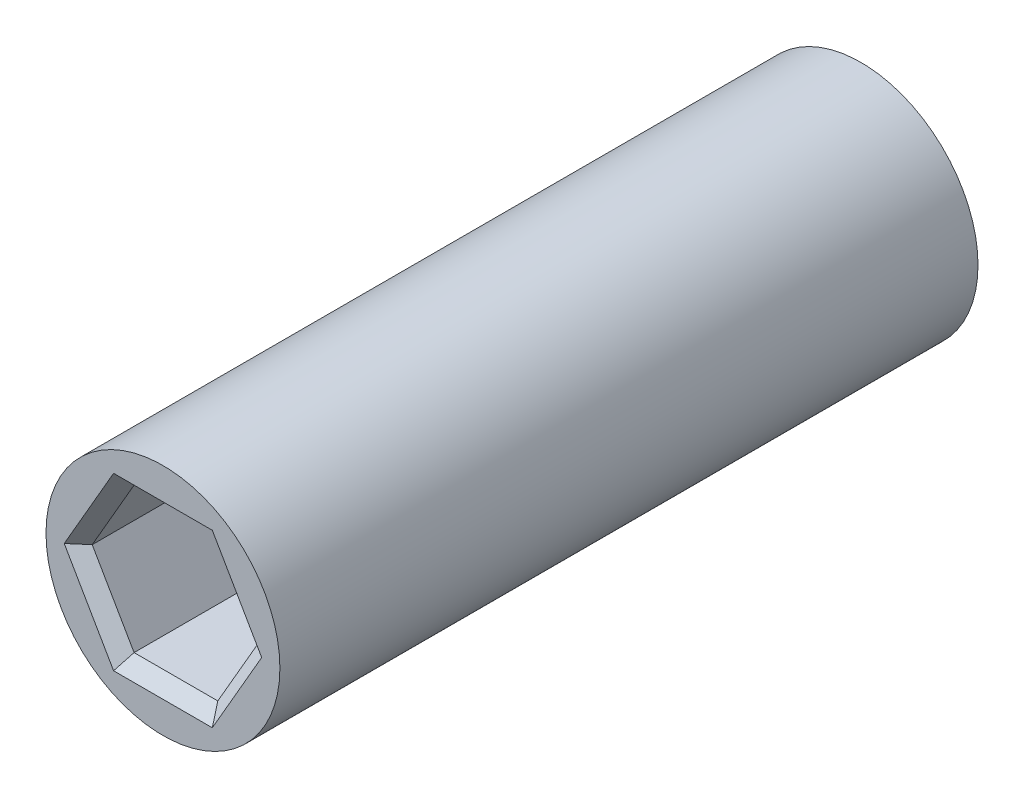
from build123d import *

# Parameters (mm, degrees)
SKETCH1_W          = 4.5
SKETCH1_H          = 26.85997733
CUT_EXTRUDE1_DEPTH = 7
CUT_EXTRUDE2_DEPTH = 7
CHAMFER1_SIZE      = 0.5
CUT_EXTRUDE3_DEPTH = 1


with BuildPart() as part:
    # Sketch1 → Revolve-Thin1 (revolve)
    with BuildSketch(Plane(origin=(0, 0, 0), x_dir=(1, 0, 0), z_dir=(0, 1, 0))):
        with Locations((2.25, 30.929988665)):
            Rectangle(SKETCH1_W, SKETCH1_H)
    revolve(axis=Axis((0, 0, 0), (0, 0, -1)))

    # Sketch2 → Cut-Extrude1 (cut)
    with BuildSketch(Plane.XY.offset(-17.5)):
        Polygon((1.610807251, 2.79), (-1.610807251, 2.79), (-3.221614502, 0), (-1.610807251, -2.79), (1.610807251, -2.79), (3.221614502, 0), align=None)
    extrude(amount=-CUT_EXTRUDE1_DEPTH, mode=Mode.SUBTRACT)

    # Sketch3 → Cut-Extrude2 (cut)
    with BuildSketch(Plane(origin=(0, 0, -44.35997733), x_dir=(-1, 0, 0), z_dir=(0, 0, -1))):
        Polygon((1.610807251, 2.79), (-1.610807251, 2.79), (-3.221614502, 0), (-1.610807251, -2.79), (1.610807251, -2.79), (3.221614502, 0), align=None)
    extrude(amount=-CUT_EXTRUDE2_DEPTH, mode=Mode.SUBTRACT)

    # Chamfer1
    chamfer1_edges = [part.edges().sort_by_distance(p)[0] for p in [
        (2.416210877, 1.395, -17.5),
        (0, 2.79, -17.5),
        (-2.416210877, 1.395, -17.5),
        (-2.416210877, -1.395, -17.5),
        (0, -2.79, -17.5),
        (2.416210877, -1.395, -17.5),
        (-2.416210877, 1.395, -44.35997733),
        (0, 2.79, -44.35997733),
        (2.416210877, 1.395, -44.35997733),
        (2.416210877, -1.395, -44.35997733),
        (0, -2.79, -44.35997733),
        (-2.416210877, -1.395, -44.35997733),
    ]]
    chamfer(chamfer1_edges, length=CHAMFER1_SIZE)

    # Sketch4 → Cut-Extrude3 (cut)
    with BuildSketch(Plane(origin=(0, -4.5, 0), x_dir=(1, 0, 0), z_dir=(0, 1, 0))):
        with BuildLine():
            Line((-0.735236378, 34.104988665), (-0.183809095, 34.104988665))
            add(Edge.make_bspline(
                [(-0.183809095, 34.104988665), (-0.142887229, 34.104821435), (-0.063984952, 34.104498996), (0.049479088, 34.099913909), (0.153619775, 34.092996425), (0.248313279, 34.083867435), (0.333638661, 34.071201473), (0.40941848, 34.055993448), (0.47613676, 34.039057193), (0.516147477, 34.02331892), (0.534890825, 34.015946197)],
                knots=[0, 0, 0, 0, 0.000122758, 0.000236692, 0.000340599, 0.000435844, 0.000522015, 0.000599225, 0.000667726, 0.000728098, 0.000728098, 0.000728098, 0.000728098], degree=3))
            add(Edge.make_bspline(
                [(0.534890825, 34.015946197), (0.555993425, 34.006429933), (0.597245667, 33.987827142), (0.656357727, 33.95629427), (0.711711569, 33.922324809), (0.762389804, 33.884637999), (0.8094619, 33.84482071), (0.852635966, 33.802494227), (0.891564361, 33.757008969), (0.926655631, 33.709180776), (0.957858636, 33.659071505), (0.984643202, 33.606434054), (1.007803352, 33.551714066), (1.025889509, 33.49431609), (1.04092128, 33.434929127), (1.050643284, 33.373178483), (1.057485172, 33.309272455), (1.058047365, 33.265888615), (1.058333333, 33.243820796)],
                knots=[0, 0, 0, 0, 6.9431e-05, 0.000135726, 0.000200852, 0.000264074, 0.000324989, 0.000385705, 0.00044524, 0.000504393, 0.000563519, 0.000622115, 0.000681412, 0.000741551, 0.000802483, 0.00086501, 0.000928929, 0.000995103, 0.000995103, 0.000995103, 0.000995103], degree=3))
            add(Edge.make_bspline(
                [(1.058333333, 33.243820796), (1.057660809, 33.216664827), (1.056333136, 33.163054546), (1.047657842, 33.083998974), (1.031477343, 33.008136947), (1.009687089, 32.93522949), (0.982690716, 32.864804536), (0.947875359, 32.798087533), (0.907633136, 32.733916018), (0.861157476, 32.67313132), (0.809209736, 32.61517584), (0.749228296, 32.563460322), (0.684531415, 32.51450675), (0.612461254, 32.471597247), (0.53499992, 32.431738139), (0.45038063, 32.397967081), (0.360191554, 32.366801607), (0.296952619, 32.351203721), (0.264583333, 32.343219835)],
                knots=[0, 0, 0, 0, 8.1472e-05, 0.00016084, 0.000238178, 0.00031384, 0.000388957, 0.000464053, 0.000539224, 0.00061593, 0.000693367, 0.000772226, 0.000853128, 0.000936463, 0.001023502, 0.00111421, 0.001209545, 0.001309511, 0.001309511, 0.001309511, 0.001309511], degree=3))
            Line((0.264583333, 32.343219835), (0.997275641, 30.929988665))
            Line((0.997275641, 30.929988665), (0.360621995, 30.929988665))
            Line((0.360621995, 30.929988665), (-0.356805889, 32.313963024))
            Line((-0.356805889, 32.313963024), (-0.41023137, 32.313963024))
            Line((-0.41023137, 32.313963024), (-0.605488782, 30.929988665))
            Line((-0.605488782, 30.929988665), (-1.180448718, 30.929988665))
            Line((-1.180448718, 30.929988665), (-0.735236378, 34.104988665))
        make_face()
        with BuildLine():
            add(Edge.make_bspline(
                [(-0.335817308, 32.843129691), (-0.294894066, 32.843508532), (-0.2166182, 32.84423316), (-0.104827079, 32.849303715), (-0.004219131, 32.857224722), (0.08509361, 32.868749131), (0.16339231, 32.882182886), (0.230523904, 32.899038904), (0.286593934, 32.919072013), (0.332485643, 32.942831056), (0.369661123, 32.970726112), (0.40183809, 33.00049459), (0.428631207, 33.033817084), (0.450737928, 33.070134204), (0.467788114, 33.109521218), (0.480083934, 33.152244969), (0.486882391, 33.198020591), (0.487927508, 33.229595041), (0.488461538, 33.245728849)],
                knots=[0, 0, 0, 0, 0.000122766, 0.000234821, 0.000335651, 0.000425427, 0.000504898, 0.000573853, 0.000632811, 0.000683169, 0.0007282, 0.000771845, 0.000814359, 0.000856026, 0.000899036, 0.000942718, 0.000989043, 0.001037447, 0.001037447, 0.001037447, 0.001037447], degree=3))
            add(Edge.make_bspline(
                [(0.488461538, 33.245728849), (0.487770257, 33.264022258), (0.486429265, 33.299508964), (0.474830234, 33.35062006), (0.454996287, 33.39698474), (0.427122393, 33.438159863), (0.392337213, 33.474465682), (0.349901429, 33.504369125), (0.300298842, 33.527903238), (0.253836196, 33.543471254), (0.210053836, 33.552396101), (0.169082237, 33.558639509), (0.120514754, 33.564294057), (0.064292994, 33.568668304), (0.000652546, 33.571550346), (-0.070576621, 33.574306307), (-0.149461846, 33.575296954), (-0.204585812, 33.575641686), (-0.23341847, 33.575821998)],
                knots=[0, 0, 0, 0, 5.483e-05, 0.000106364, 0.000156221, 0.00020526, 0.000254739, 0.000306272, 0.000360034, 0.000418964, 0.000452769, 0.000493968, 0.000543275, 0.000599421, 0.000663102, 0.000734382, 0.000813258, 0.000899759, 0.000899759, 0.000899759, 0.000899759], degree=3))
            Line((-0.23341847, 33.575821998), (-0.335817308, 32.843129691))
        make_face(mode=Mode.SUBTRACT)
    extrude(amount=CUT_EXTRUDE3_DEPTH, mode=Mode.SUBTRACT)


solid = part.part
